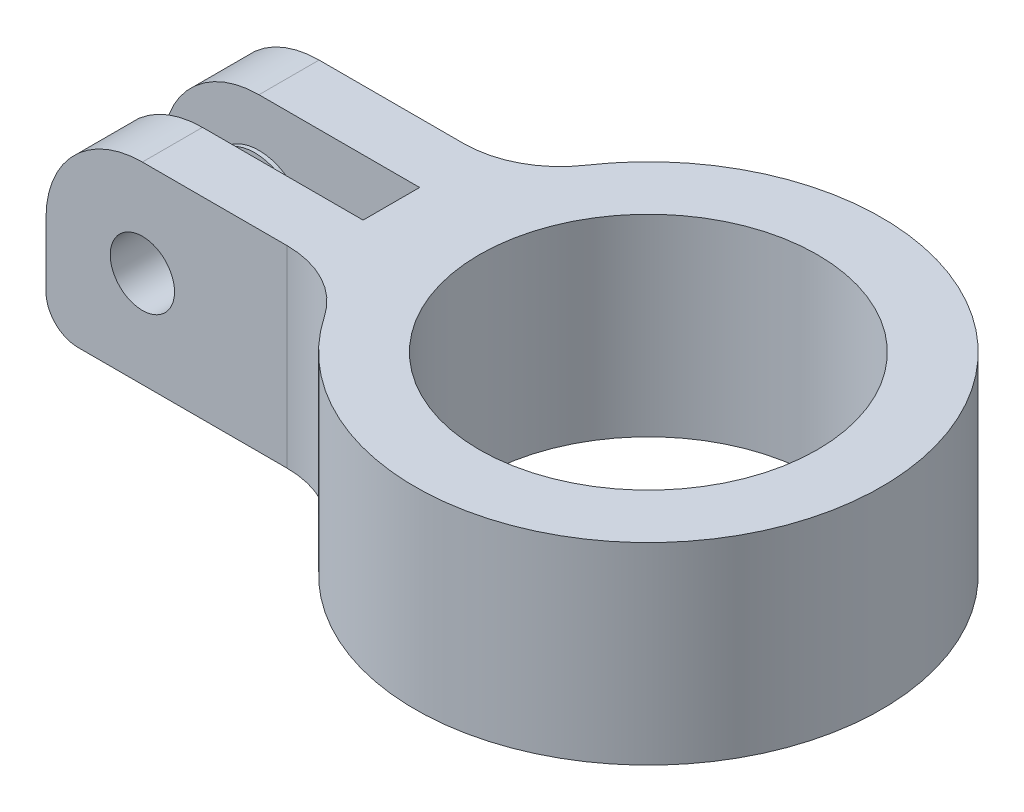
from build123d import *

# Parameters (mm, degrees)
SKETCH1_R           = 16.7005
BOSS_EXTRUDE1_DEPTH = 19.05
SKETCH2_R           = 3.175
CUT_EXTRUDE1_DEPTH  = 63.87783499
SKETCH2_3_R         = 4.7625
SKETCH2_3_R_2       = 3.175
BOSS_EXTRUDE2_DEPTH = 6.35
FILLET1_R           = 9.525
FILLET2_R           = 3.175


with BuildPart() as part:
    # Sketch1 → Boss-Extrude1 (new body)
    with BuildSketch(Plane(origin=(0, 0, 0), x_dir=(1, 0, 0), z_dir=(0, 1, 0))):
        with BuildLine():
            Line((-50.8, 8.73125), (-50.8, 2.794))
            Line((-50.8, 2.794), (-25.4, 2.794))
            Line((-25.4, 2.794), (-25.4, -2.794))
            Line((-25.4, -2.794), (-50.8, -2.794))
            Line((-50.8, -2.794), (-50.8, -8.73125))
            Line((-50.8, -8.73125), (-21.332857842, -8.73125))
            ThreePointArc((-21.332857842, -8.73125), (23.0505, 0), (-21.332857842, 8.73125))
            Line((-21.332857842, 8.73125), (-50.8, 8.73125))
        make_face()
        Circle(SKETCH1_R, mode=Mode.SUBTRACT)
    extrude(amount=BOSS_EXTRUDE1_DEPTH)

    # Sketch2 → Cut-Extrude1 (cut, through all)
    with BuildSketch(Plane.XY.offset(8.73125)):
        with Locations((-41.275, 9.525)):
            Circle(SKETCH2_R)
    extrude(amount=-CUT_EXTRUDE1_DEPTH, mode=Mode.SUBTRACT)

    # Sketch2_3 → Boss-Extrude2 (add)
    with BuildSketch(Plane.XY.offset(8.73125)):
        with Locations((-41.275, 9.525)):
            Circle(SKETCH2_3_R)
        with Locations((-41.275, 9.525)):
            Circle(SKETCH2_3_R_2, mode=Mode.SUBTRACT)
    boss_extrude2 = extrude(amount=-BOSS_EXTRUDE2_DEPTH)

    # Mirror1: Boss-Extrude2 across plane
    add(boss_extrude2.mirror(Plane.XY))

    # Fillet1
    fillet1_edges = [part.edges().sort_by_distance(p)[0] for p in [
        (-21.332857842, 9.525, 8.73125),
        (-21.332857842, 9.525, -8.73125),
        (-50.8, 19.05, -5.762625),
        (-50.8, 19.05, 5.762625),
    ]]
    fillet(fillet1_edges, radius=FILLET1_R)

    # Fillet2
    fillet2_edges = [part.edges().sort_by_distance(p)[0] for p in [
        (-50.8, 0, 5.762625),
        (-50.8, 0, -5.762625),
    ]]
    fillet(fillet2_edges, radius=FILLET2_R)


solid = part.part
